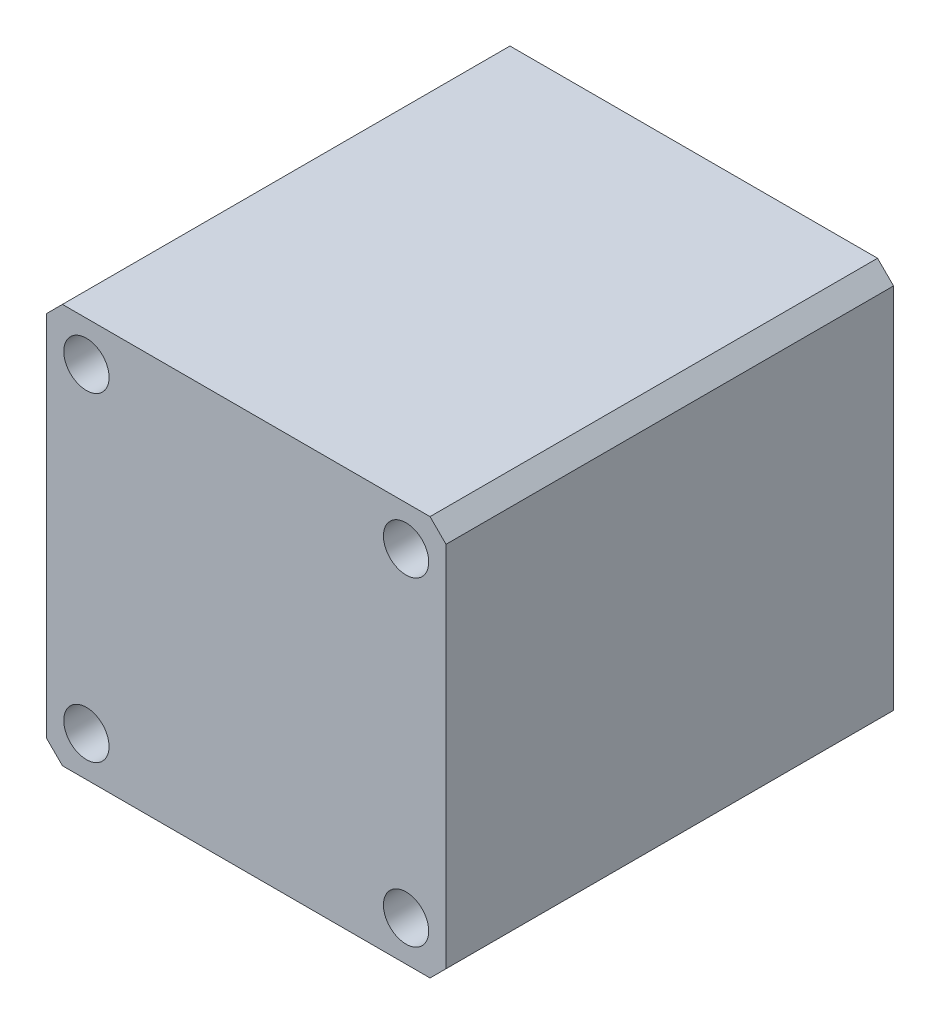
from build123d import *

# Parameters (mm, degrees)
SKETCH_1_W          = 75
SKETCH_1_H          = 75
EXTRUDE_1_DEPTH     = 84
CHAMFER_1_SIZE      = 3
SKETCH_2_R          = 4.25
CUT_EXTRUDE_1_DEPTH = 85


with BuildPart() as part:
    # 草图1 → 凸台-拉伸1 (new body)
    with BuildSketch(Plane.XY):
        with Locations((37.5, -37.5)):
            Rectangle(SKETCH_1_W, SKETCH_1_H)
    extrude(amount=EXTRUDE_1_DEPTH)

    # 倒角1
    chamfer_1_edges = [part.edges().sort_by_distance(p)[0] for p in [
        (0, 0, 42),
        (75, 0, 42),
        (75, -75, 42),
        (0, -75, 42),
    ]]
    chamfer(chamfer_1_edges, length=CHAMFER_1_SIZE)

    # 草图2 → 切除-拉伸1 (cut, through all)
    with BuildSketch(Plane.XY.offset(84)):
        with Locations((7.5, -7.5)):
            Circle(SKETCH_2_R)
        with Locations((67.5, -7.5)):
            Circle(SKETCH_2_R)
        with Locations((67.5, -67.5)):
            Circle(SKETCH_2_R)
        with Locations((7.5, -67.5)):
            Circle(SKETCH_2_R)
    extrude(amount=-CUT_EXTRUDE_1_DEPTH, mode=Mode.SUBTRACT)


solid = part.part
